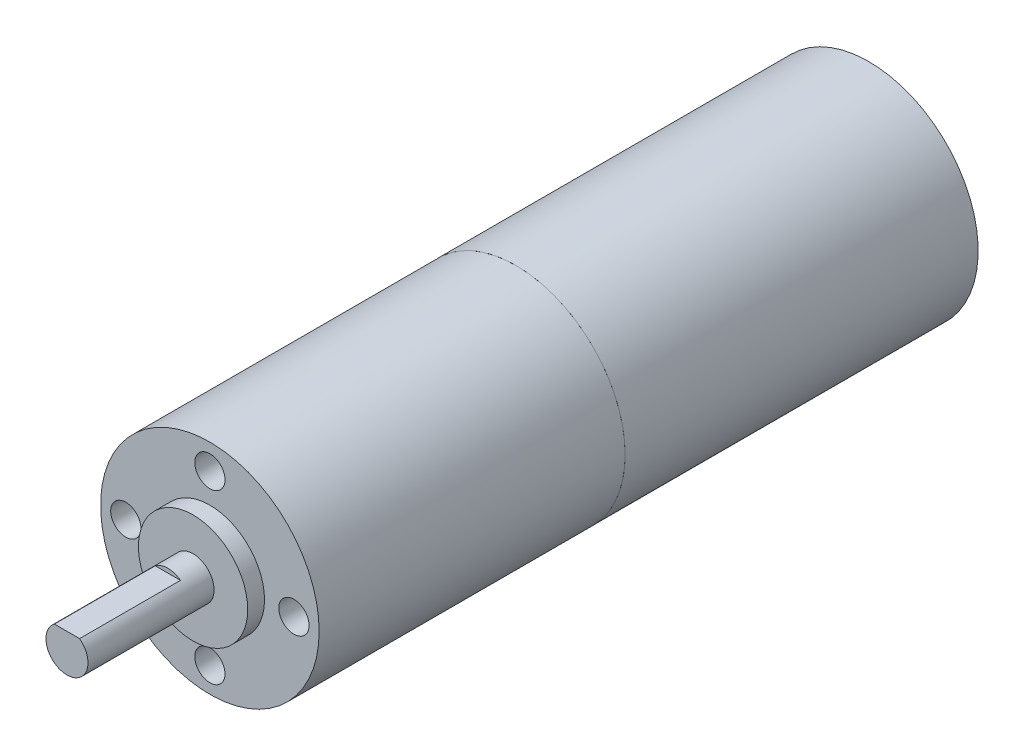
from build123d import *

# Parameters (mm, degrees)
ESQUISSE1_R                = 13
BOSS_EXTRU_REDUCTEUR_DEPTH = 36.4
ESQUISSE2_R                = 2.5
BOSS_EXTRU_ARBRE_DEPTH     = 17
ESQUISSE4_R                = 6.5
ESQUISSE4_R_2              = 2.5
BOSS_EXTRU_3_DEPTH         = 2
ESQUISSE5_R                = 1.8
ENL_V_MAT_EXTRU_2_DEPTH    = 4
ENL_V_MAT_EXTRU_3_DEPTH    = 12
ESQUISSE7_R                = 2.496805343
BOSS_EXTRU_4_DEPTH         = 3
ESQUISSE9_R                = 13
BOSS_EXTRU_5_DEPTH         = 42


with BuildPart() as part:
    # Esquisse1 → Boss.-Extru. Reducteur (new body)
    with BuildSketch(Plane.XY):
        Circle(ESQUISSE1_R)
    extrude(amount=BOSS_EXTRU_REDUCTEUR_DEPTH)

    # Esquisse2 → Boss.-Extru. Arbre (add)
    with BuildSketch(Plane.XY.offset(36.4)):
        Circle(ESQUISSE2_R)
    extrude(amount=BOSS_EXTRU_ARBRE_DEPTH)

    # Esquisse4 → Boss.-Extru.3 (add)
    with BuildSketch(Plane.XY.offset(36.4)):
        Circle(ESQUISSE4_R)
        Circle(ESQUISSE4_R_2, mode=Mode.SUBTRACT)
    extrude(amount=BOSS_EXTRU_3_DEPTH)

    # Esquisse5 → Enlèv. mat.-Extru.2 (cut)
    with BuildSketch(Plane.XY.offset(36.4)):
        with Locations((0, 10)):
            Circle(ESQUISSE5_R)
        with Locations((-10, 0)):
            Circle(ESQUISSE5_R)
        with Locations((0, -10)):
            Circle(ESQUISSE5_R)
        with Locations((10, 0)):
            Circle(ESQUISSE5_R)
    extrude(amount=-ENL_V_MAT_EXTRU_2_DEPTH, mode=Mode.SUBTRACT)

    # Esquisse6 → Enlèv. mat.-Extru.3 (cut)
    with BuildSketch(Plane.XY.offset(53.4)):
        with BuildLine():
            Line((0, 2), (1.5, 2))
            ThreePointArc((1.5, 2), (0, 2.5), (-1.5, 2))
            Line((-1.5, 2), (0, 2))
        make_face()
    extrude(amount=-ENL_V_MAT_EXTRU_3_DEPTH, mode=Mode.SUBTRACT)


with BuildPart() as body_2:
    # Esquisse7 → Boss.-Extru.4 (new body)
    with BuildSketch(Plane.XY.offset(36.4)):
        Circle(ESQUISSE7_R)
    extrude(amount=BOSS_EXTRU_4_DEPTH)


with BuildPart() as body_3:
    # Esquisse9 → Boss.-Extru.5 (new body)
    with BuildSketch(Plane(origin=(0, 0, 0), x_dir=(-1, 0, 0), z_dir=(0, 0, -1))):
        Circle(ESQUISSE9_R)
    extrude(amount=BOSS_EXTRU_5_DEPTH)


solid = Compound([part.part, body_2.part, body_3.part])
